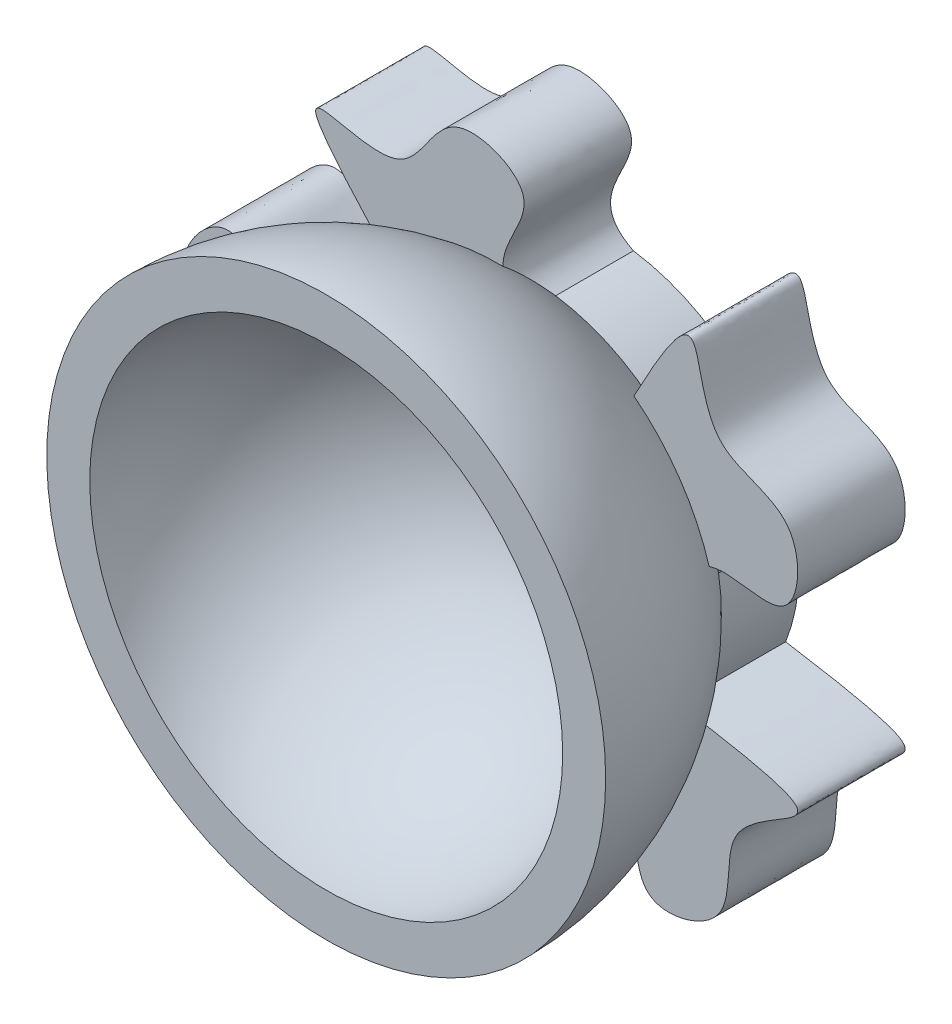
from build123d import *

# Parameters (mm, degrees)
BOSS_EXTRUDE3_DEPTH = 10


with BuildPart() as part:
    # Sketch6 → Revolve2 (revolve)
    with BuildSketch(Plane(origin=(0, 0, 0), x_dir=(1, 0, 0), z_dir=(0, 1, 0))):
        with BuildLine():
            Line((-22, 0), (-26, 0))
            ThreePointArc((-26, 0), (-23.916521486, 10.198039027), (-18, 18.761663039))
            Line((-18, 18.761663039), (-18, 26))
            Line((-18, 26), (0, 26))
            Line((0, 26), (0, 22))
            ThreePointArc((0, 22), (-15.556349186, 15.556349186), (-22, 0))
        make_face()
    revolve(axis=Axis((0, 0, 0), (0, 0, -1)))

    # Sketch9 → Boss-Extrude3 (add)
    with BuildSketch(Plane(origin=(0, 0, -26), x_dir=(-1, 0, 0), z_dir=(0, 0, -1))):
        with BuildLine():
            ThreePointArc((17.429093033, -4.49741215), (17.904928082, 1.847579597), (16.143457304, 7.961707496))
            add(Edge.make_bspline(
                [(16.143457304, 7.961707496), (20.14808294, 3.958191849), (23.5849466, 14.798196674), (31.717081229, 4.844150904), (21.239967464, -2.834572011), (35.221538741, -13.510467446), (17.429093033, -4.49741215)],
                knots=[0, 0, 0, 0, 0.25171063, 0.412803204, 0.599959487, 1, 1, 1, 1], degree=3))
        make_face()
        with BuildLine():
            ThreePointArc((9.663179076, 15.186275717), (3.775774445, 17.59953202), (-2.58343114, 17.813643186))
            add(Edge.make_bspline(
                [(-2.58343114, 17.813643186), (2.477431693, 20.409282016), (-6.82609533, 26.941816039), (5.372149051, 31.827749855), (8.685963717, 18.10380345), (24.013315636, 30.586526517), (9.663179076, 15.186275717)],
                knots=[0, 0, 0, 0, 0.249531615, 0.409229639, 0.599394581, 1, 1, 1, 1], degree=3))
        make_face()
        with BuildLine():
            ThreePointArc((1.108592812, -17.965829287), (7.290079676, -16.457665032), (12.56063645, -12.893037344))
            add(Edge.make_bspline(
                [(12.56063645, -12.893037344), (9.990564184, -17.938817023), (21.362070687, -17.857722892), (14.408178395, -28.667811828), (3.867672725, -21.076340386), (-1.965164064, -37.672637976), (1.108592812, -17.965829287)],
                knots=[0, 0, 0, 0, 0.25171063, 0.412803204, 0.599959487, 1, 1, 1, 1], degree=3))
        make_face()
        with BuildLine():
            ThreePointArc((-16.743944996, -6.606080986), (-13.399411062, -12.018975963), (-8.380557058, -15.930042793))
            add(Edge.make_bspline(
                [(-8.380557058, -15.930042793), (-13.973574708, -15.044990487), (-10.382460845, -25.834876383), (-22.812337265, -22.561832997), (-18.849614263, -10.191322706), (-36.436076926, -9.772503269), (-16.743944996, -6.606080986)],
                knots=[0, 0, 0, 0, 0.25171063, 0.412803204, 0.599959487, 1, 1, 1, 1], degree=3))
        make_face()
        with BuildLine():
            ThreePointArc((-11.456919925, 13.883046706), (-15.571371141, 9.029529377), (-17.740105557, 3.047729456))
            add(Edge.make_bspline(
                [(-17.740105557, 3.047729456), (-18.626708298, 8.640501541), (-27.778784376, 1.890891192), (-28.506978187, 14.723832188), (-15.517375014, 14.777756563), (-20.553569893, 31.632898801), (-11.456919925, 13.883046706)],
                knots=[0, 0, 0, 0, 0.25171063, 0.412803204, 0.599959487, 1, 1, 1, 1], degree=3))
        make_face()
    extrude(amount=-BOSS_EXTRUDE3_DEPTH)


solid = part.part
